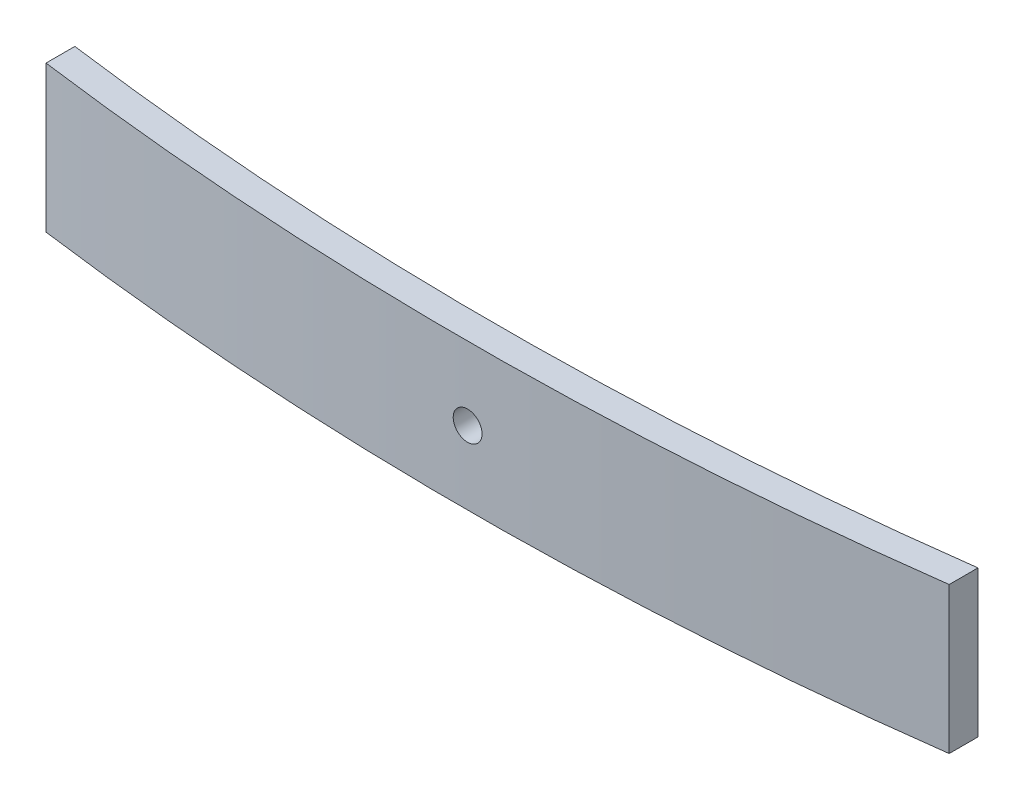
from build123d import *

# Parameters (mm, degrees)
BOSS_EXTRUDE1_DEPTH = 76.2
SKETCH13_R          = 7.5
CUT_EXTRUDE1_DEPTH  = 269


with BuildPart() as part:
    # Sketch1 → Boss-Extrude1 (new body)
    with BuildSketch(Plane(origin=(0, 0, 0), x_dir=(1, 0, 0), z_dir=(0, 1, 0))):
        with BuildLine():
            ThreePointArc((235.021699517, -237.381311512), (0, -253), (-235.021699517, -237.381311512))
            Line((-235.021699517, -237.381311512), (-235.021699517, -252.381311512))
            ThreePointArc((-235.021699517, -252.381311512), (0, -268), (235.021699517, -252.381311512))
            Line((235.021699517, -252.381311512), (235.021699517, -237.381311512))
        make_face()
    extrude(amount=BOSS_EXTRUDE1_DEPTH)

    # Sketch13 → Cut-Extrude1 (cut, through all)
    with BuildSketch(Plane.XY):
        with Locations((0, 38.1)):
            Circle(SKETCH13_R)
    extrude(amount=CUT_EXTRUDE1_DEPTH, mode=Mode.SUBTRACT)


solid = part.part
